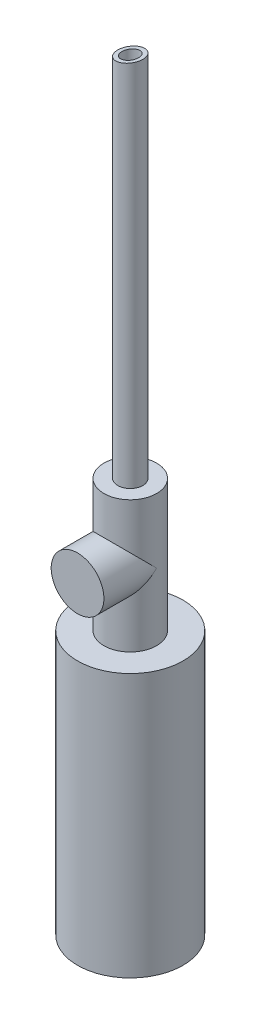
from build123d import *

# Parameters (mm, degrees)
CROQUIS1_R                 = 2.38135
CROQUIS1_R_2               = 1.5875
SALIENTE_EXTRUIR1_DEPTH    = 70
CORTAR_EXTRUIR1_DEPTH      = 3.38135
CORTAR_EXTRUIR1_DEPTH_BACK = 3.38135
CROQUIS3_R                 = 5
CROQUIS3_R_2               = 1.5875
SALIENTE_EXTRUIR2_DEPTH    = 25
CROQUIS4_R                 = 10
CROQUIS4_R_2               = 1.5875
SALIENTE_EXTRUIR3_DEPTH    = 50
CROQUIS5_R                 = 5
SALIENTE_EXTRUIR4_DEPTH    = 10


with BuildPart() as part:
    # Croquis1 → Saliente-Extruir1 (new body)
    with BuildSketch(Plane(origin=(0, 0, 0), x_dir=(1, 0, 0), z_dir=(0, 1, 0))):
        Circle(CROQUIS1_R)
        Circle(CROQUIS1_R_2, mode=Mode.SUBTRACT)
    extrude(amount=SALIENTE_EXTRUIR1_DEPTH)

    # Croquis2 → Cortar-Extruir1 (cut, two sides)
    with BuildSketch(Plane.XY) as cortar_extruir1_sk:
        Polygon((2.38135, 70), (-2.38135, 70), (-2.38135, 69.160207489), align=None)
    extrude(amount=CORTAR_EXTRUIR1_DEPTH, mode=Mode.SUBTRACT)
    extrude(cortar_extruir1_sk.sketch, amount=-CORTAR_EXTRUIR1_DEPTH_BACK, mode=Mode.SUBTRACT)

    # Croquis3 → Saliente-Extruir2 (add)
    with BuildSketch(Plane.XZ):
        Circle(CROQUIS3_R)
        Circle(CROQUIS3_R_2, mode=Mode.SUBTRACT)
    extrude(amount=SALIENTE_EXTRUIR2_DEPTH)

    # Croquis4 → Saliente-Extruir3 (add)
    with BuildSketch(Plane.XZ.offset(25)):
        Circle(CROQUIS4_R)
        Circle(CROQUIS4_R_2, mode=Mode.SUBTRACT)
    extrude(amount=SALIENTE_EXTRUIR3_DEPTH)

    # Croquis5 → Saliente-Extruir4 (add)
    with BuildSketch(Plane.XY):
        with Locations((0, -12.25)):
            Circle(CROQUIS5_R)
    extrude(amount=SALIENTE_EXTRUIR4_DEPTH)


solid = part.part
